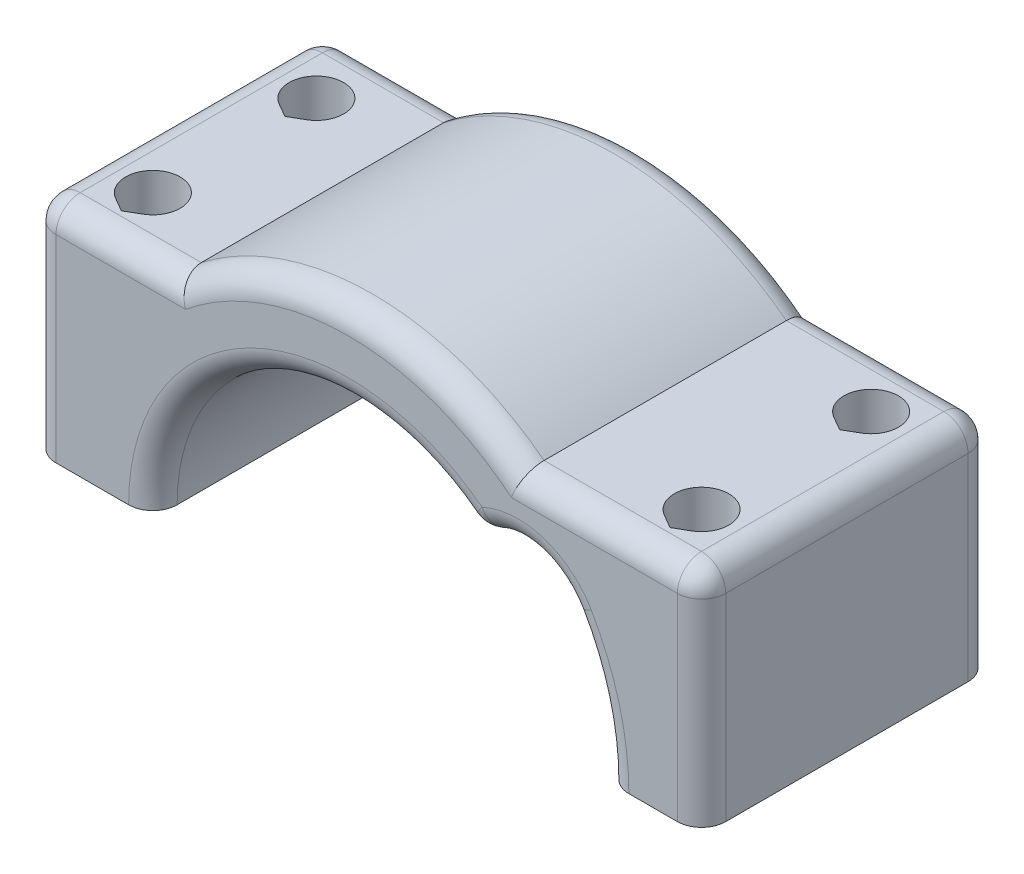
from build123d import *

# Parameters (mm, degrees)
AUFSATZ_LINEAR_AUSTRAGEN1_DEPTH = 12
SCHNITT_LINEAR_AUSTRAGEN1_DEPTH = 37.46124655
SCHNITT_LINEAR_AUSTRAGEN2_DEPTH = 37.46124655
SCHNITT_LINEAR_AUSTRAGEN3_DEPTH = 37.46124655
VERRUNDUNG1_R                   = 2
VERRUNDUNG2_R                   = 2


with BuildPart() as part:
    # Skizze1 → Aufsatz-Linear austragen1 (new, symmetric)
    with BuildSketch(Plane.XY):
        with BuildLine():
            ThreePointArc((18.31643729, 10.575), (20.429331226, 5.474022804), (21.15, 0))
            Line((21.15, 0), (29.15, 0))
            Line((29.15, 0), (29.15, 18.322117782))
            Line((29.15, 18.322117782), (14.15, 18.322117782))
            ThreePointArc((14.15, 18.322117782), (0, 23.15), (-14.15, 18.322117782))
            Line((-14.15, 18.322117782), (-26.15, 18.322117782))
            Line((-26.15, 18.322117782), (-26.15, 0))
            Line((-26.15, 0), (-16.15, 0))
            ThreePointArc((-16.15, 0), (-6.544357391, 14.764616024), (10.846146915, 11.965934861))
            ThreePointArc((10.846146915, 11.965934861), (14.901557957, 12.990518454), (18.31643729, 10.575))
        make_face()
    extrude(amount=AUFSATZ_LINEAR_AUSTRAGEN1_DEPTH, both=True)

    # Skizze2 → Schnitt-Linear austragen1 (cut, through all)
    with BuildSketch(Plane(origin=(0, 18.322117782, 0), x_dir=(1, 0, 0), z_dir=(0, 1, 0))):
        with BuildLine():
            Line((-22.275, 4.551442841), (-21.15, 3.901923789))
            Line((-21.15, 3.901923789), (-20.025, 4.551442841))
            ThreePointArc((-20.025, 4.551442841), (-21.15, 8.75), (-22.275, 4.551442841))
        make_face()
    extrude(amount=-SCHNITT_LINEAR_AUSTRAGEN1_DEPTH, mode=Mode.SUBTRACT)

    # Skizze2_4 → Schnitt-Linear austragen2 (cut, through all)
    with BuildSketch(Plane(origin=(0, 18.322117782, 0), x_dir=(1, 0, 0), z_dir=(0, 1, 0))):
        with BuildLine():
            Line((23.025, 5.051442841), (24.15, 4.401923789))
            Line((24.15, 4.401923789), (25.275, 5.051442841))
            ThreePointArc((25.275, 5.051442841), (24.15, 9.25), (23.025, 5.051442841))
        make_face()
    extrude(amount=-SCHNITT_LINEAR_AUSTRAGEN2_DEPTH, mode=Mode.SUBTRACT)

    # Skizze2_5 → Schnitt-Linear austragen3 (cut, through all)
    with BuildSketch(Plane(origin=(0, 18.322117782, 0), x_dir=(1, 0, 0), z_dir=(0, 1, 0))):
        with BuildLine():
            Line((24.15, -9.598076211), (25.275, -8.948557159))
            ThreePointArc((25.275, -8.948557159), (24.15, -4.75), (23.025, -8.948557159))
            Line((23.025, -8.948557159), (24.15, -9.598076211))
        make_face()
        with BuildLine():
            Line((-22.275, -8.948557159), (-21.15, -9.598076211))
            Line((-21.15, -9.598076211), (-20.025, -8.948557159))
            ThreePointArc((-20.025, -8.948557159), (-21.15, -4.75), (-22.275, -8.948557159))
        make_face()
    extrude(amount=-SCHNITT_LINEAR_AUSTRAGEN3_DEPTH, mode=Mode.SUBTRACT)

    # Verrundung1
    verrundung1_edges = [part.edges().sort_by_distance(p)[0] for p in [
        (20.429331226, 5.474022804, 12),
        (20.429331226, 5.474022804, -12),
        (10.846146915, 11.965934861, 0),
        (14.901557957, 12.990518454, 12),
        (14.901557957, 12.990518454, -12),
        (29.15, 9.161058891, -12),
        (29.15, 9.161058891, 12),
        (-26.15, 9.161058891, -12),
        (-26.15, 9.161058891, 12),
        (-6.544357391, 14.764616024, -12),
        (-6.544357391, 14.764616024, 12),
    ]]
    fillet(verrundung1_edges, radius=VERRUNDUNG1_R)

    # Verrundung2
    verrundung2_edges = [part.edges().sort_by_distance(p)[0] for p in [
        (20.65, 18.322117782, 12),
        (28.564213562, 18.322117782, 11.414213562),
        (20.65, 18.322117782, -12),
        (28.564213562, 18.322117782, -11.414213562),
        (-19.15, 18.322117782, 12),
        (-25.564213562, 18.322117782, 11.414213562),
        (-19.15, 18.322117782, -12),
        (-25.564213562, 18.322117782, -11.414213562),
        (0, 23.15, -12),
        (0, 23.15, 12),
        (29.15, 18.322117782, 0),
        (-26.15, 18.322117782, 0),
    ]]
    fillet(verrundung2_edges, radius=VERRUNDUNG2_R)


solid = part.part
